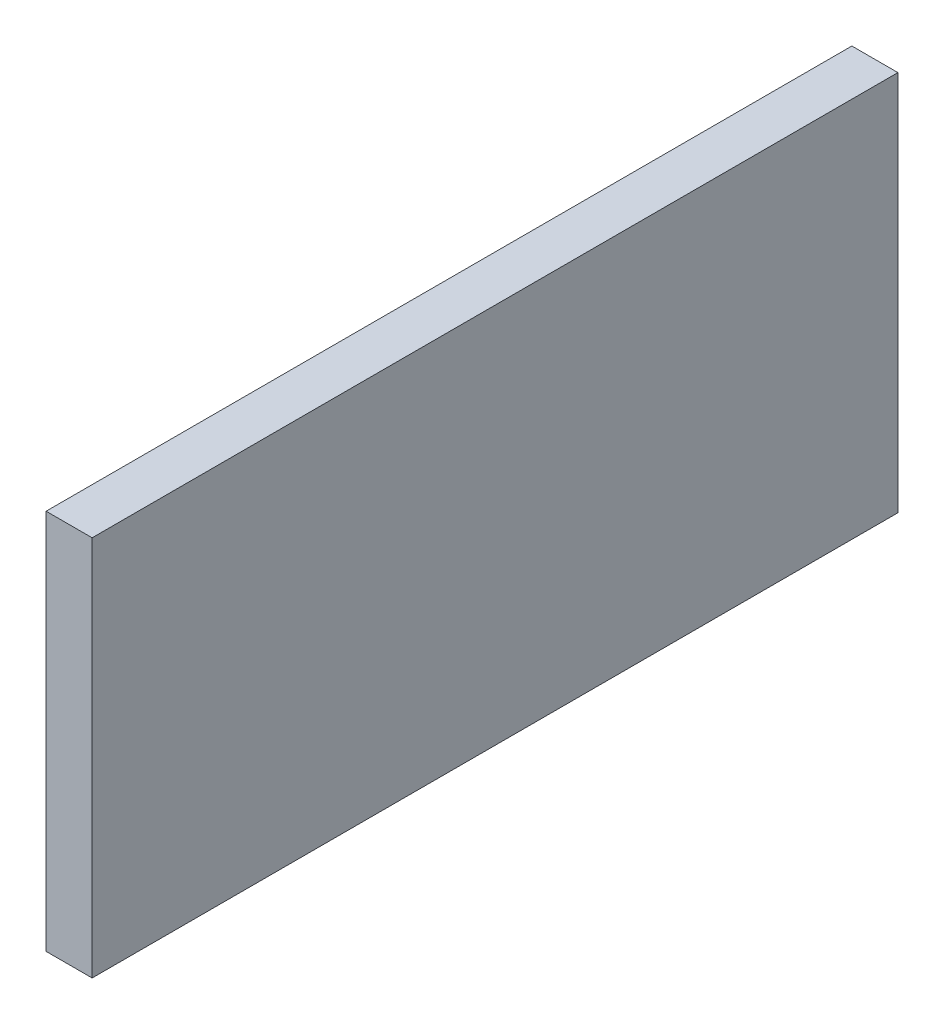
from build123d import *

# Parameters (mm, degrees)
SKETCH1_W           = 2.54
SKETCH1_H           = 44.45
BOSS_EXTRUDE1_DEPTH = 21.0312


with BuildPart() as part:
    # Sketch1 → Boss-Extrude1 (new body)
    with BuildSketch(Plane(origin=(0, 0, 0), x_dir=(1, 0, 0), z_dir=(0, 1, 0))):
        with Locations((1.27, 22.225)):
            Rectangle(SKETCH1_W, SKETCH1_H)
    extrude(amount=BOSS_EXTRUDE1_DEPTH)


solid = part.part
